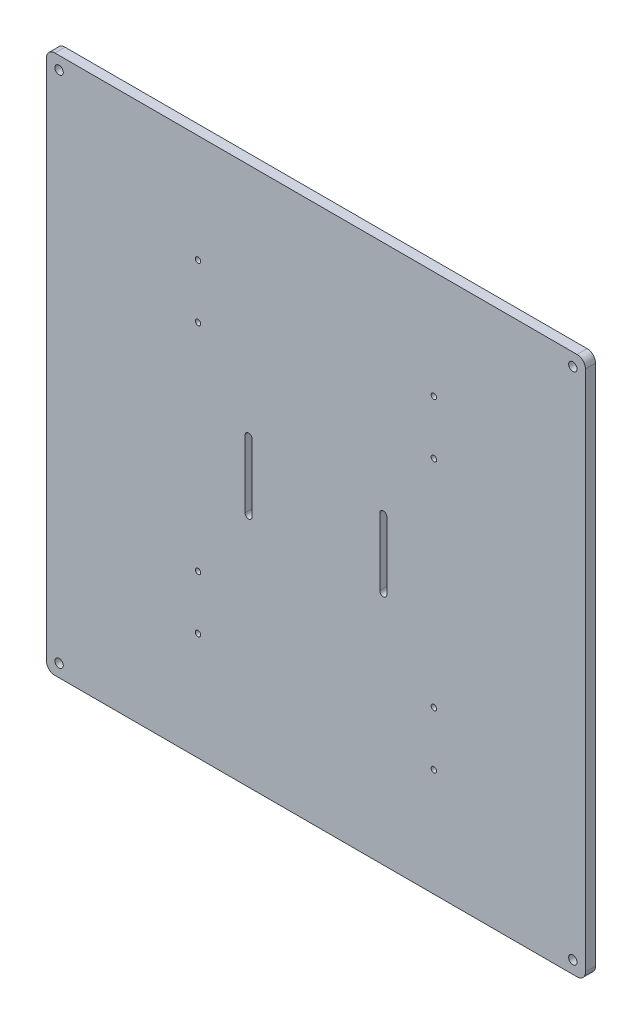
from build123d import *

# Parameters (mm, degrees)
ESQUISSE1_W        = 320
ESQUISSE1_H        = 320
ESQUISSE1_R        = 2.5
BOSS_EXTRU_1_DEPTH = 6
CONG_3_R           = 5
CONG_4_R           = 5
CONG_5_R           = 5
CONG_6_R           = 5
SKETCH1_R          = 1.6
CUT_EXTRUDE1_DEPTH = 7
CUT_EXTRUDE2_DEPTH = 7


with BuildPart() as part:
    # Esquisse1 → Boss.-Extru.1 (new body)
    with BuildSketch(Plane.XY):
        with Locations((160, 160)):
            Rectangle(ESQUISSE1_W, ESQUISSE1_H)
        with Locations((7.5, 312.5)):
            Circle(ESQUISSE1_R, mode=Mode.SUBTRACT)
        with Locations((312.5, 312.5)):
            Circle(ESQUISSE1_R, mode=Mode.SUBTRACT)
        with Locations((7.5, 7.5)):
            Circle(ESQUISSE1_R, mode=Mode.SUBTRACT)
        with Locations((312.5, 7.5)):
            Circle(ESQUISSE1_R, mode=Mode.SUBTRACT)
    extrude(amount=BOSS_EXTRU_1_DEPTH)

    # Congé3
    cong_3_edges = [part.edges().sort_by_distance(p)[0] for p in [
        (0, 320, 3),
    ]]
    fillet(cong_3_edges, radius=CONG_3_R)

    # Congé4
    cong_4_edges = [part.edges().sort_by_distance(p)[0] for p in [
        (0, 0, 3),
    ]]
    fillet(cong_4_edges, radius=CONG_4_R)

    # Congé5
    cong_5_edges = [part.edges().sort_by_distance(p)[0] for p in [
        (320, 320, 3),
    ]]
    fillet(cong_5_edges, radius=CONG_5_R)

    # Congé6
    cong_6_edges = [part.edges().sort_by_distance(p)[0] for p in [
        (320, 0, 3),
    ]]
    fillet(cong_6_edges, radius=CONG_6_R)

    # Sketch1 → Cut-Extrude1 (cut, through all)
    with BuildSketch(Plane.XY.offset(6)):
        with Locations((90, 224)):
            Circle(SKETCH1_R)
        with Locations((230, 224)):
            Circle(SKETCH1_R)
        with Locations((90, 96)):
            Circle(SKETCH1_R)
        with Locations((230, 96)):
            Circle(SKETCH1_R)
        with Locations((90, 256)):
            Circle(SKETCH1_R)
        with Locations((90, 64)):
            Circle(SKETCH1_R)
        with Locations((230, 64)):
            Circle(SKETCH1_R)
        with Locations((230, 256)):
            Circle(SKETCH1_R)
    extrude(amount=-CUT_EXTRUDE1_DEPTH, mode=Mode.SUBTRACT)

    # Sketch3 → Cut-Extrude2 (cut, through all)
    with BuildSketch(Plane(origin=(0, 0, 0), x_dir=(-1, 0, 0), z_dir=(0, 0, -1))):
        with BuildLine():
            Line((-197.9, 180), (-197.9, 140))
            ThreePointArc((-197.9, 140), (-200, 137.9), (-202.1, 140))
            Line((-202.1, 140), (-202.1, 180))
            ThreePointArc((-202.1, 180), (-200, 182.1), (-197.9, 180))
        make_face()
        with BuildLine():
            Line((-117.9, 180), (-117.9, 140))
            ThreePointArc((-117.9, 140), (-120, 137.9), (-122.1, 140))
            Line((-122.1, 140), (-122.1, 180))
            ThreePointArc((-122.1, 180), (-120, 182.1), (-117.9, 180))
        make_face()
    extrude(amount=-CUT_EXTRUDE2_DEPTH, mode=Mode.SUBTRACT)


solid = part.part
